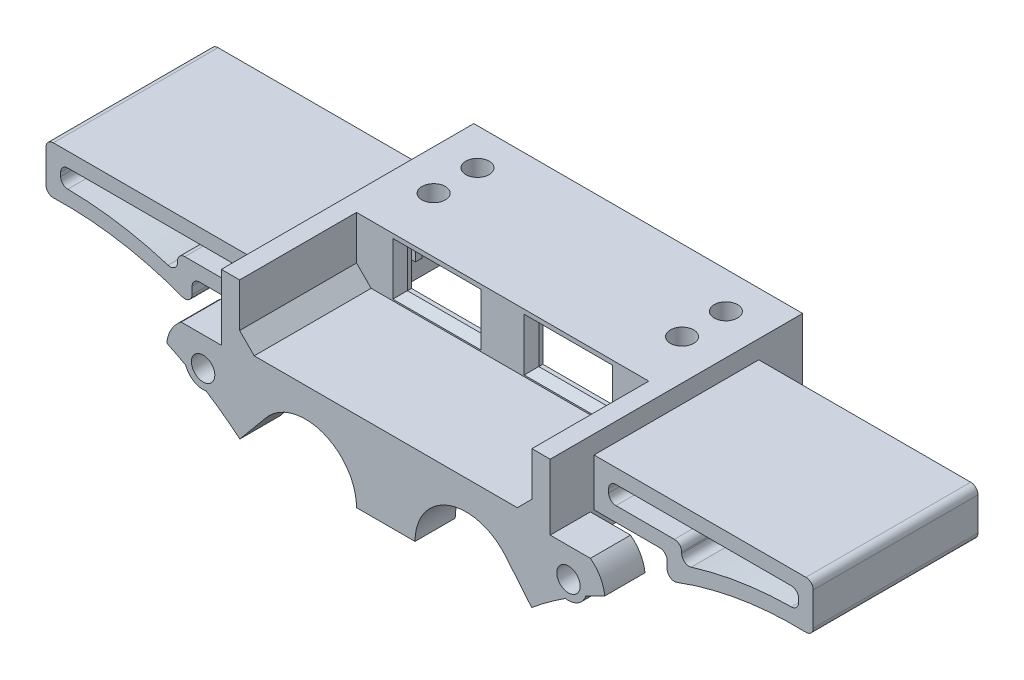
from build123d import *

# Parameters (mm, degrees)
EXTRUDE_1_DEPTH     = 34.55
SKETCH_2_W          = 40
SKETCH_2_H          = 8
CUT_EXTRUDE_1_DEPTH = 16
CUT_EXTRUDE_2_DEPTH = 10
SKETCH_4_W          = 10.1
SKETCH_4_H          = 5.2
CUT_EXTRUDE_3_DEPTH = 10
CHAMFER_1_SIZE      = 2
CHAMFER_2_SIZE      = 1
SKETCH_6_R          = 1.6
EXTRUDE_2_DEPTH     = 6.9
SKETCH_7_R          = 1.6
CUT_EXTRUDE_4_DEPTH = 10
SKETCH_8_R          = 1.6
EXTRUDE_3_DEPTH     = 5.5
SKETCH_10_W         = 40
SKETCH_10_H         = 10
CUT_EXTRUDE_5_DEPTH = 2
CUT_EXTRUDE_6_DEPTH = 10
SKETCH_12_W         = 34
SKETCH_12_H         = 2.5
CUT_EXTRUDE_7_DEPTH = 4.9
EXTRUDE_START       = -6
EXTRUDE_4_DEPTH     = 22.55
FILLET_1_R          = 1


with BuildPart() as part:
    # 草图1 → 凸台-拉伸1 (new body)
    with BuildSketch(Plane.XY):
        Polygon((0, 0), (22.5, 0), (22.5, 12), (-22.5, 12), (-22.5, 0), align=None)
    extrude(amount=EXTRUDE_1_DEPTH)

    # 草图2 → 切除-拉伸1 (cut)
    with BuildSketch(Plane.XY.offset(34.55)):
        with Locations((0, 8)):
            Rectangle(SKETCH_2_W, SKETCH_2_H)
    extrude(amount=-CUT_EXTRUDE_1_DEPTH, mode=Mode.SUBTRACT)

    # 草图3 → 切除-拉伸2 (cut)
    with BuildSketch(Plane.XZ):
        Polygon((0, 2), (20, 2), (20, 17), (-20, 17), (-20, 2), align=None)
    extrude(amount=-CUT_EXTRUDE_2_DEPTH, mode=Mode.SUBTRACT)

    # 草图4 → 切除-拉伸3 (cut)
    with BuildSketch(Plane.XY.offset(18.55)):
        with Locations((-8.99, 7.8)):
            Rectangle(SKETCH_4_W, SKETCH_4_H)
        with Locations((8.99, 7.8)):
            Rectangle(SKETCH_4_W, SKETCH_4_H)
    extrude(amount=-CUT_EXTRUDE_3_DEPTH, mode=Mode.SUBTRACT)

    # 倒角1
    chamfer_1_edges = [part.edges().sort_by_distance(p)[0] for p in [
        (20, 4, 26.55),
        (-20, 4, 26.55),
    ]]
    chamfer(chamfer_1_edges, length=CHAMFER_1_SIZE)

    # 倒角2
    chamfer_2_edges = [part.edges().sort_by_distance(p)[0] for p in [
        (-8.99, 10.4, 18.55),
        (-14.04, 7.8, 18.55),
        (-8.99, 5.2, 18.55),
        (-3.94, 7.8, 18.55),
        (3.94, 7.8, 18.55),
        (8.99, 5.2, 18.55),
        (14.04, 7.8, 18.55),
        (8.99, 10.4, 18.55),
    ]]
    chamfer(chamfer_2_edges, length=CHAMFER_2_SIZE)

    # 草图6 → 凸台-拉伸2 (add)
    with BuildSketch(Plane(origin=(0, 12, 0), x_dir=(1, 0, 0), z_dir=(0, 1, 0))):
        with BuildLine():
            Line((22.5, 0), (22.5, -13.5))
            Line((22.5, -13.5), (17, -13.5))
            ThreePointArc((17, -13.5), (15.232233047, -12.767766953), (14.5, -11))
            Line((14.5, -11), (14.5, -5))
            Line((14.5, -5), (14.5, 0))
            Line((14.5, 0), (22.5, 0))
        make_face()
        with Locations((17, -5)):
            Circle(SKETCH_6_R, mode=Mode.SUBTRACT)
        with Locations((17, -11)):
            Circle(SKETCH_6_R, mode=Mode.SUBTRACT)
        with BuildLine():
            Line((-14.5, 0), (-22.5, 0))
            Line((-22.5, 0), (-22.5, -13.5))
            Line((-22.5, -13.5), (-17, -13.5))
            ThreePointArc((-17, -13.5), (-15.232233047, -12.767766953), (-14.5, -11))
            Line((-14.5, -11), (-14.5, -5))
            Line((-14.5, -5), (-14.5, 0))
        make_face()
        with Locations((-17, -11)):
            Circle(SKETCH_6_R, mode=Mode.SUBTRACT)
        with Locations((-17, -5)):
            Circle(SKETCH_6_R, mode=Mode.SUBTRACT)
    extrude(amount=-EXTRUDE_2_DEPTH)

    # 草图7 → 切除-拉伸4 (cut)
    with BuildSketch(Plane(origin=(0, 12, 0), x_dir=(1, 0, 0), z_dir=(0, 1, 0))):
        with Locations((17, -5)):
            Circle(SKETCH_7_R)
        with Locations((17, -11)):
            Circle(SKETCH_7_R)
        with Locations((-17, -5)):
            Circle(SKETCH_7_R)
        with Locations((-17, -11)):
            Circle(SKETCH_7_R)
    extrude(amount=-CUT_EXTRUDE_4_DEPTH, mode=Mode.SUBTRACT)

    # 草图8 → 凸台-拉伸3 (add)
    with BuildSketch(Plane.XY.offset(34.55)):
        with BuildLine():
            Line((1.843049286, -25.367101461), (9.230566594, -19.615105309))
            ThreePointArc((9.230566594, -19.615105309), (9.814108465, -18.625953935), (10.421644381, -17.651355727))
            Line((10.421644381, -17.651355727), (5.476763257, -11.300448334))
            ThreePointArc((5.476763257, -11.300448334), (6.699551666, -1.476763257), (16.523236743, -2.699551666))
            Line((16.523236743, -2.699551666), (19.967990067, -6.846461039))
            ThreePointArc((19.967990067, -6.846461039), (22.224318463, -5.085470923), (24.58365332, -3.465087309))
            ThreePointArc((24.58365332, -3.465087309), (26.278709649, -3.148232211), (27.365383934, -1.809295278))
            ThreePointArc((27.365383934, -1.809295278), (28.658809968, -1.124546474), (29.972928279, -0.480399834))
            ThreePointArc((29.972928279, -0.480399834), (29.349734714, 1.46572665), (28, 3))
            Line((28, 3), (22.5, 3))
            Line((22.5, 3), (22.5, 4))
            Line((22.5, 4), (-22.5, 4))
            Line((-22.5, 4), (-22.5, 3))
            Line((-22.5, 3), (-28, 3))
            ThreePointArc((-28, 3), (-29.349734714, 1.46572665), (-29.972928279, -0.480399834))
            ThreePointArc((-29.972928279, -0.480399834), (-28.658809968, -1.124546474), (-27.365383934, -1.809295278))
            ThreePointArc((-27.365383934, -1.809295278), (-26.278709649, -3.148232211), (-24.58365332, -3.465087309))
            ThreePointArc((-24.58365332, -3.465087309), (-22.224318463, -5.085470923), (-19.967990067, -6.846461039))
            Line((-19.967990067, -6.846461039), (-16.523236743, -2.699551666))
            ThreePointArc((-16.523236743, -2.699551666), (-6.699551666, -1.476763257), (-5.476763257, -11.300448334))
            Line((-5.476763257, -11.300448334), (-10.421644381, -17.651355727))
            ThreePointArc((-10.421644381, -17.651355727), (-9.814108465, -18.625953935), (-9.230566594, -19.615105309))
            Line((-9.230566594, -19.615105309), (-1.843049286, -25.367101461))
            ThreePointArc((-1.843049286, -25.367101461), (0, -26), (1.843049286, -25.367101461))
        make_face()
        with Locations((25, -1)):
            Circle(SKETCH_8_R, mode=Mode.SUBTRACT)
        with Locations((0, -23)):
            Circle(SKETCH_8_R, mode=Mode.SUBTRACT)
        with Locations((-25, -1)):
            Circle(SKETCH_8_R, mode=Mode.SUBTRACT)
    extrude(amount=-EXTRUDE_3_DEPTH)

    # 草图10 → 切除-拉伸5 (cut)
    with BuildSketch(Plane(origin=(0, 0, 0), x_dir=(-1, 0, 0), z_dir=(0, 0, -1))):
        with Locations((0, 5)):
            Rectangle(SKETCH_10_W, SKETCH_10_H)
    extrude(amount=-CUT_EXTRUDE_5_DEPTH, mode=Mode.SUBTRACT)

    # 草图11 → 切除-拉伸6 (cut)
    with BuildSketch(Plane(origin=(0, 0, 29.05), x_dir=(-1, 0, 0), z_dir=(0, 0, -1))):
        Polygon((-4, -7), (4, -7), (10.421644381, -17.651355727), (10.421644381, -27.0891889), (-10.421644381, -27.0891889), (-10.421644381, -17.651355727), align=None)
    extrude(amount=-CUT_EXTRUDE_6_DEPTH, mode=Mode.SUBTRACT)

    # 草图12 → 切除-拉伸7 (cut)
    with BuildSketch(Plane.XZ.offset(-5.1)):
        with Locations((0, 12.25)):
            Rectangle(SKETCH_12_W, SKETCH_12_H)
    extrude(amount=-CUT_EXTRUDE_7_DEPTH, mode=Mode.SUBTRACT)

    # 草图14 → 凸台-拉伸4 (add)
    with BuildSketch(Plane(origin=(0, 0, 0), x_dir=(-1, 0, 0), z_dir=(0, 0, -1)).offset(EXTRUDE_START)):
        with BuildLine():
            Line((-22.5, 9.5), (-52.5, 9.5))
            Line((-52.5, 9.5), (-52.5, 2.932014979))
            ThreePointArc((-52.5, 2.932014979), (-42.310755549, 2.352789548), (-32.5, -0.458843457))
            Line((-32.5, -0.458843457), (-32.5, 3))
            Line((-32.5, 3), (-22.5, 3))
            Line((-22.5, 3), (-22.5, 9.5))
        make_face()
        with BuildLine():
            Line((-24.5, 7.5), (-50.5, 7.5))
            Line((-50.5, 7.5), (-50.5, 4.997395763))
            ThreePointArc((-50.5, 4.997395763), (-42.390809061, 4.393039713), (-34.5, 2.428515274))
            Line((-34.5, 2.428515274), (-34.5, 5))
            Line((-34.5, 5), (-24.5, 5))
            Line((-24.5, 5), (-24.5, 7.5))
        make_face(mode=Mode.SUBTRACT)
        with BuildLine():
            Line((32.5, 3), (32.5, -0.458843457))
            ThreePointArc((32.5, -0.458843457), (42.310755549, 2.352789548), (52.5, 2.932014979))
            Line((52.5, 2.932014979), (52.5, 9.5))
            Line((52.5, 9.5), (22.5, 9.5))
            Line((22.5, 9.5), (22.5, 3))
            Line((22.5, 3), (32.5, 3))
        make_face()
        with BuildLine():
            Line((34.5, 5), (34.5, 2.428515274))
            ThreePointArc((34.5, 2.428515274), (42.390809061, 4.393039713), (50.5, 4.997395763))
            Line((50.5, 4.997395763), (50.5, 7.5))
            Line((50.5, 7.5), (24.5, 7.5))
            Line((24.5, 7.5), (24.5, 5))
            Line((24.5, 5), (34.5, 5))
        make_face(mode=Mode.SUBTRACT)
    extrude(amount=-EXTRUDE_4_DEPTH)

    # 圆角1
    fillet_1_edges = [part.edges().sort_by_distance(p)[0] for p in [
        (32.5, 3, 17.275),
        (32.5, -0.458843457, 17.275),
        (52.5, 2.932014979, 17.275),
        (52.5, 9.5, 17.275),
        (24.5, 5, 17.275),
        (34.5, 5, 17.275),
        (34.5, 2.428515274, 17.275),
        (50.5, 4.997395763, 17.275),
        (50.5, 7.5, 17.275),
        (24.5, 7.5, 17.275),
        (-52.5, 2.932014979, 17.275),
        (-32.5, -0.458843457, 17.275),
        (-32.5, 3, 17.275),
        (-52.5, 9.5, 17.275),
        (-24.5, 5, 17.275),
        (-24.5, 7.5, 17.275),
        (-50.5, 7.5, 17.275),
        (-50.5, 4.997395763, 17.275),
        (-34.5, 2.428515274, 17.275),
        (-34.5, 5, 17.275),
    ]]
    fillet(fillet_1_edges, radius=FILLET_1_R)


solid = part.part
